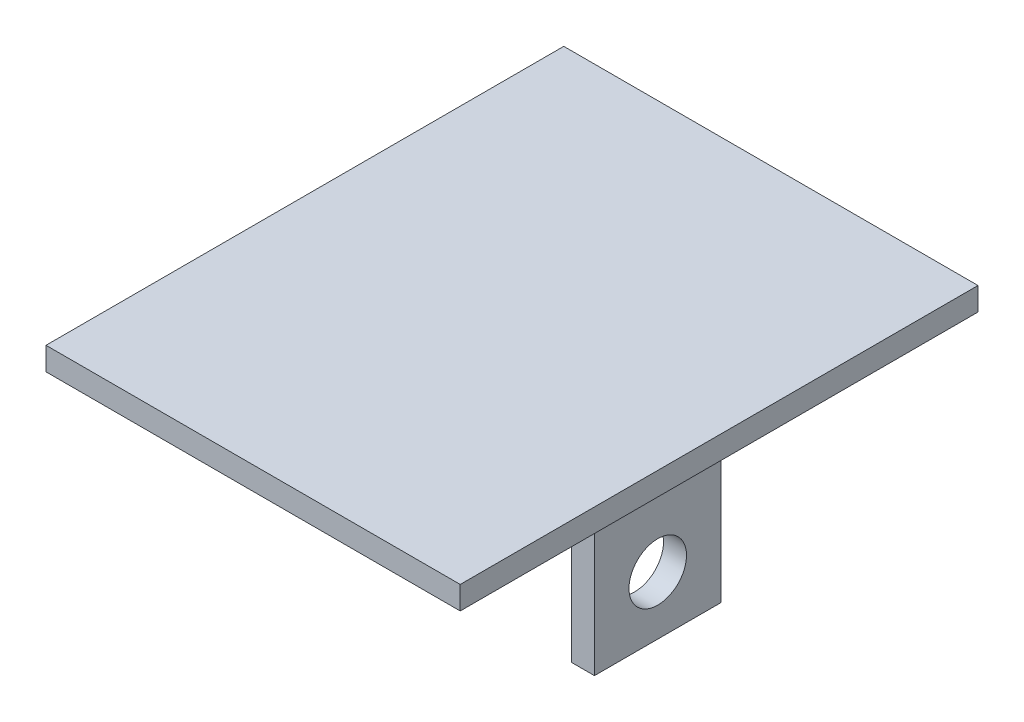
from build123d import *

# Parameters (mm, degrees)
CROQUIS1_W              = 36
CROQUIS1_H              = 45
SALIENTE_EXTRUIR1_DEPTH = 2
CROQUIS2_W              = 2
CROQUIS2_H              = 11
CROQUIS2_H_2            = 11.033856499
SALIENTE_EXTRUIR2_DEPTH = 18
CROQUIS3_R              = 2.5
CORTAR_EXTRUIR1_DEPTH   = 33


with BuildPart() as part:
    # Croquis1 → Saliente-Extruir1 (new body)
    with BuildSketch(Plane(origin=(0, 0, 0), x_dir=(1, 0, 0), z_dir=(0, 1, 0))):
        Rectangle(CROQUIS1_W, CROQUIS1_H)
    extrude(amount=SALIENTE_EXTRUIR1_DEPTH)

    # Croquis2 → Saliente-Extruir2 (add)
    with BuildSketch(Plane(origin=(0, 2, 0), x_dir=(1, 0, 0), z_dir=(0, 1, 0))):
        with Locations((11.7, -0.033856499)):
            Rectangle(CROQUIS2_W, CROQUIS2_H)
        with Locations((-16, -0.01692825)):
            Rectangle(CROQUIS2_W, CROQUIS2_H_2)
    extrude(amount=-SALIENTE_EXTRUIR2_DEPTH)

    # Croquis3 → Cortar-Extruir1 (cut)
    with BuildSketch(Plane(origin=(12.7, 0, 0), x_dir=(0, 0, -1), z_dir=(1, 0, 0))):
        with Locations((-0.033856499, -10.94)):
            Circle(CROQUIS3_R)
    extrude(amount=-CORTAR_EXTRUIR1_DEPTH, mode=Mode.SUBTRACT)


solid = part.part
